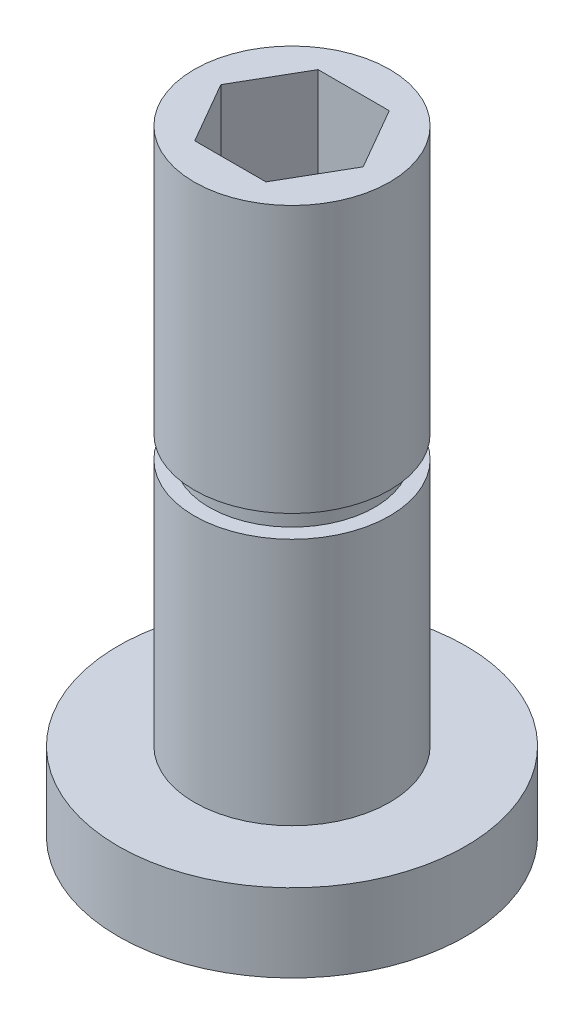
from build123d import *

# Parameters (mm, degrees)
SKETCH1_R                                     = 8.89
TRAINGULAR_BASE_SIMPLIFIED_TO_CIRCLE_HE_DEPTH = 4
SKETCH2_R                                     = 5
DRIVE_SHAFT_DEPTH                             = 27.5
SKETCH4_R                                     = 5
SKETCH4_R_2                                   = 4.238
RETAINING_RING_SLOT_DEPTH                     = 1.143
HEX_SLOT_DEPTH                                = 11.049


with BuildPart() as part:
    # Sketch1 → Traingular base (simplified to circle here) (new body)
    with BuildSketch(Plane(origin=(0, 0, 0), x_dir=(1, 0, 0), z_dir=(0, 1, 0))):
        Circle(SKETCH1_R)
    extrude(amount=TRAINGULAR_BASE_SIMPLIFIED_TO_CIRCLE_HE_DEPTH)

    # Sketch2 → Drive shaft (add)
    with BuildSketch(Plane(origin=(0, 4, 0), x_dir=(1, 0, 0), z_dir=(0, 1, 0))):
        Circle(SKETCH2_R)
    extrude(amount=DRIVE_SHAFT_DEPTH)

    # Sketch4 → Retaining ring slot (cut)
    with BuildSketch(Plane(origin=(0, 16.7, 0), x_dir=(1, 0, 0), z_dir=(0, 1, 0))):
        Circle(SKETCH4_R)
        Circle(SKETCH4_R_2, mode=Mode.SUBTRACT)
    extrude(amount=RETAINING_RING_SLOT_DEPTH, mode=Mode.SUBTRACT)

    # Sketch5 → Hex slot (cut)
    with BuildSketch(Plane(origin=(0, 31.5, 0), x_dir=(1, 0, 0), z_dir=(0, 1, 0))):
        Polygon((3.6449, 0), (1.82245, 3.156575994), (-1.82245, 3.156575994), (-3.6449, 0), (-1.82245, -3.156575994), (1.82245, -3.156575994), align=None)
    extrude(amount=-HEX_SLOT_DEPTH, mode=Mode.SUBTRACT)


solid = part.part
